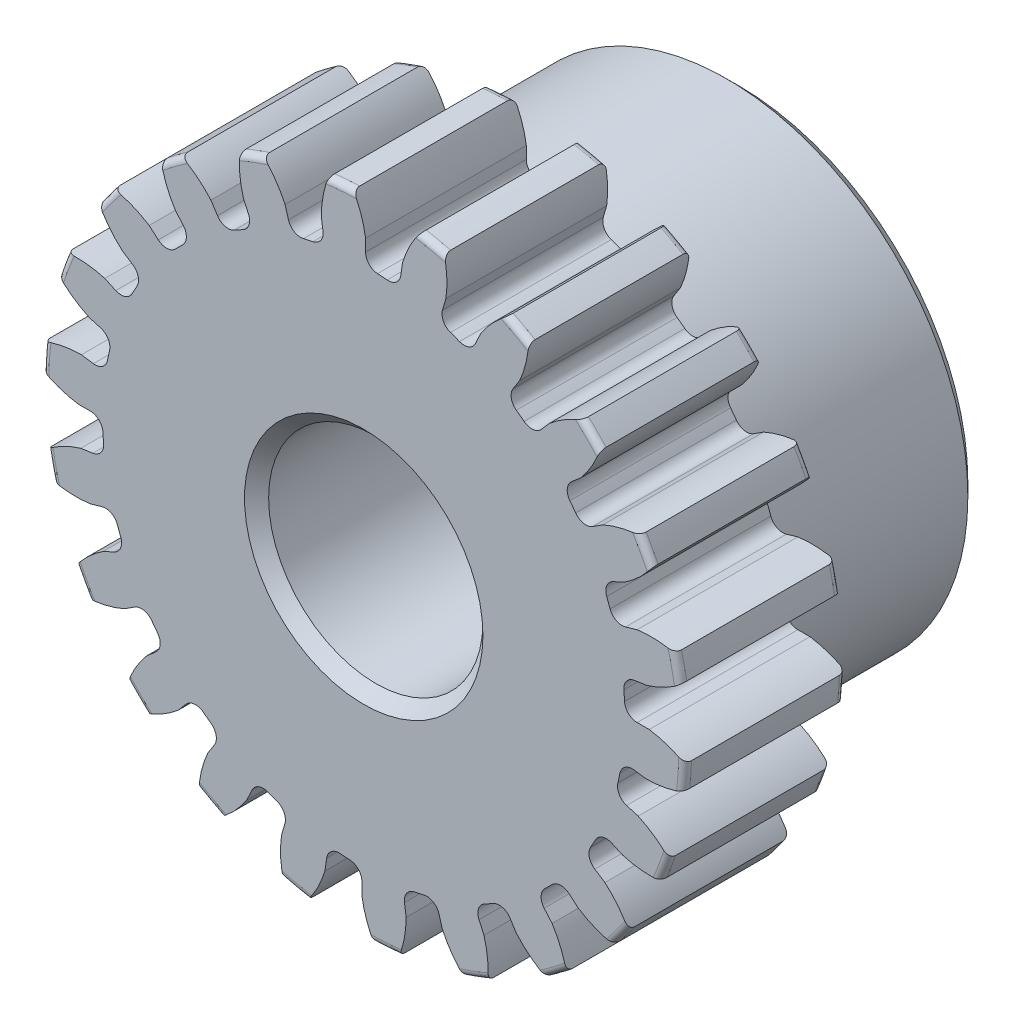
from build123d import *

# Parameters (mm, degrees)
SKETCH1_R                = 9.525
BOSS_EXTRUDE1_DEPTH      = 4.7625
SKETCH2_W                = 6.35
SKETCH2_H                = 7.14375
REVOLVE1_ANGLE           = 360
FILLET2_R                = 0.1905
CUT_EXTRUDE1_DEPTH       = 12.1125
FILLET1_R                = 0.374318784
CIRPATTERN1_COUNT        = 22
FILLET1_OF_CIRPATTERN1_R = 0.374318784
SKETCH5_R                = 3.175
CUT_EXTRUDE2_DEPTH       = 12.1125
CHAMFER1_SIZE            = 0.3571875


with BuildPart() as part:
    # Sketch1 → Boss-Extrude1 (new body)
    with BuildSketch(Plane.XY):
        Circle(SKETCH1_R)
    extrude(amount=-BOSS_EXTRUDE1_DEPTH)

    # Sketch2 → Revolve1 (revolve, symmetric)
    with BuildSketch(Plane(origin=(0, 0, 0), x_dir=(0, 0, -1), z_dir=(1, 0, 0))) as revolve1_sk:
        with Locations((7.9375, 3.571875)):
            Rectangle(SKETCH2_W, SKETCH2_H)
    revolve(axis=Axis((0, 0, -4.7625), (0, 0, -1)), revolution_arc=REVOLVE1_ANGLE / 2)
    revolve(revolve1_sk.sketch, axis=Axis((0, 0, -4.7625), (0, 0, 1)), revolution_arc=REVOLVE1_ANGLE / 2)

    # Fillet2
    fillet2_edges = [part.edges().sort_by_distance(p)[0] for p in [
        (-9.525, 0, 0),
        (-9.525, 0, -4.7625),
        (0, -7.14375, -4.7625),
    ]]
    fillet(fillet2_edges, radius=FILLET2_R)

    # Sketch4 → Cut-Extrude1 (cut, through all)
    with BuildSketch(Plane.XY):
        with BuildLine():
            Line((0.054821567, 8.459109181), (0.054821567, 7.73756943))
            ThreePointArc((0.054821567, 7.73756943), (0.552007026, 7.718048609), (1.04690994, 7.666613703))
            Line((1.04690994, 7.666613703), (1.149595991, 8.380809185))
            add(Edge.make_bspline(
                [(2.328590945, 10.036363463), (1.44460819, 9.360987761), (1.149595991, 8.380809185)],
                knots=[0, 0, 0, 1, 1, 1], degree=2))
            ThreePointArc((2.328590945, 10.036363463), (0.735006268, 10.276706337), (-0.876562375, 10.26560109))
            add(Edge.make_bspline(
                [(-0.876562375, 10.26560109), (-0.097693539, 9.471295617), (0.054821567, 8.459109181)],
                knots=[0, 0, 0, 1, 1, 1], degree=2))
        make_face()
    cut_extrude1 = extrude(amount=-CUT_EXTRUDE1_DEPTH, mode=Mode.SUBTRACT)

    # Fillet1
    fillet1_edges = [part.edges().sort_by_distance(p)[0] for p in [
        (1.04690994, 7.666613703, -2.38125),
        (0.054821567, 7.73756943, -2.38125),
    ]]
    fillet(fillet1_edges, radius=FILLET1_R)

    # CirPattern1: Cut-Extrude1 ×22 about axis
    cirpattern1_axis = Axis((0, 0, -4.7625), (0, 0, 1))
    for i in range(1, CIRPATTERN1_COUNT):
        add(cut_extrude1.rotate(cirpattern1_axis, i * 360 / CIRPATTERN1_COUNT), mode=Mode.SUBTRACT)

    # Fillet1 of CirPattern1
    fillet1_of_cirpattern1_edges = [part.edges().sort_by_distance(p)[0] for p in [
        (-1.15543195, 7.651010593, -2.38125),
        (-2.127324311, 7.439588521, -2.38125),
        (-3.264167614, 7.015568108, -2.38125),
        (-4.137127025, 6.538896396, -2.38125),
        (-5.108459831, 5.811766018, -2.38125),
        (-5.811764312, 5.108461772, -2.38125),
        (-6.538895014, 4.137129208, -2.38125),
        (-7.015567018, 3.264169957, -2.38125),
        (-7.439587811, 2.127326795, -2.38125),
        (-7.651010208, 1.155434505, -2.38125),
        (-7.737569449, -0.054818983, -2.38125),
        (-7.666614053, -1.04690738, -2.38125),
        (-7.408699226, -2.232523654, -2.38125),
        (-7.061114422, -3.164435054, -2.38125),
        (-6.479620254, -4.229362535, -2.38125),
        (-5.883565295, -5.02559902, -2.38125),
        (-5.025600985, -5.883563617, -2.38125),
        (-4.229364699, -6.479618842, -2.38125),
        (-3.164437412, -7.061113365, -2.38125),
        (-2.232526128, -7.408698481, -2.38125),
        (-1.04690994, -7.666613703, -2.38125),
        (-0.054821567, -7.73756943, -2.38125),
        (1.15543195, -7.651010593, -2.38125),
        (2.127324311, -7.439588521, -2.38125),
        (3.264167614, -7.015568108, -2.38125),
        (4.137127025, -6.538896396, -2.38125),
        (5.108459831, -5.811766018, -2.38125),
        (5.811764312, -5.108461772, -2.38125),
        (6.538895014, -4.137129208, -2.38125),
        (7.015567018, -3.264169957, -2.38125),
        (7.439587811, -2.127326795, -2.38125),
        (7.651010208, -1.155434505, -2.38125),
        (7.737569449, 0.054818983, -2.38125),
        (7.666614053, 1.04690738, -2.38125),
        (7.408699226, 2.232523654, -2.38125),
        (7.061114422, 3.164435054, -2.38125),
        (6.479620254, 4.229362535, -2.38125),
        (5.883565295, 5.02559902, -2.38125),
        (5.025600985, 5.883563617, -2.38125),
        (4.229364699, 6.479618842, -2.38125),
        (3.164437412, 7.061113365, -2.38125),
        (2.232526128, 7.408698481, -2.38125),
    ]]
    fillet(fillet1_of_cirpattern1_edges, radius=FILLET1_OF_CIRPATTERN1_R)

    # Sketch5 → Cut-Extrude2 (cut, through all)
    with BuildSketch(Plane.XY):
        Circle(SKETCH5_R)
    extrude(amount=-CUT_EXTRUDE2_DEPTH, mode=Mode.SUBTRACT)

    # Chamfer1
    chamfer1_edges = [part.edges().sort_by_distance(p)[0] for p in [
        (0, -7.14375, -11.1125),
        (-3.175, 0, -11.1125),
        (-3.175, 0, 0),
    ]]
    chamfer(chamfer1_edges, length=CHAMFER1_SIZE)


solid = part.part
